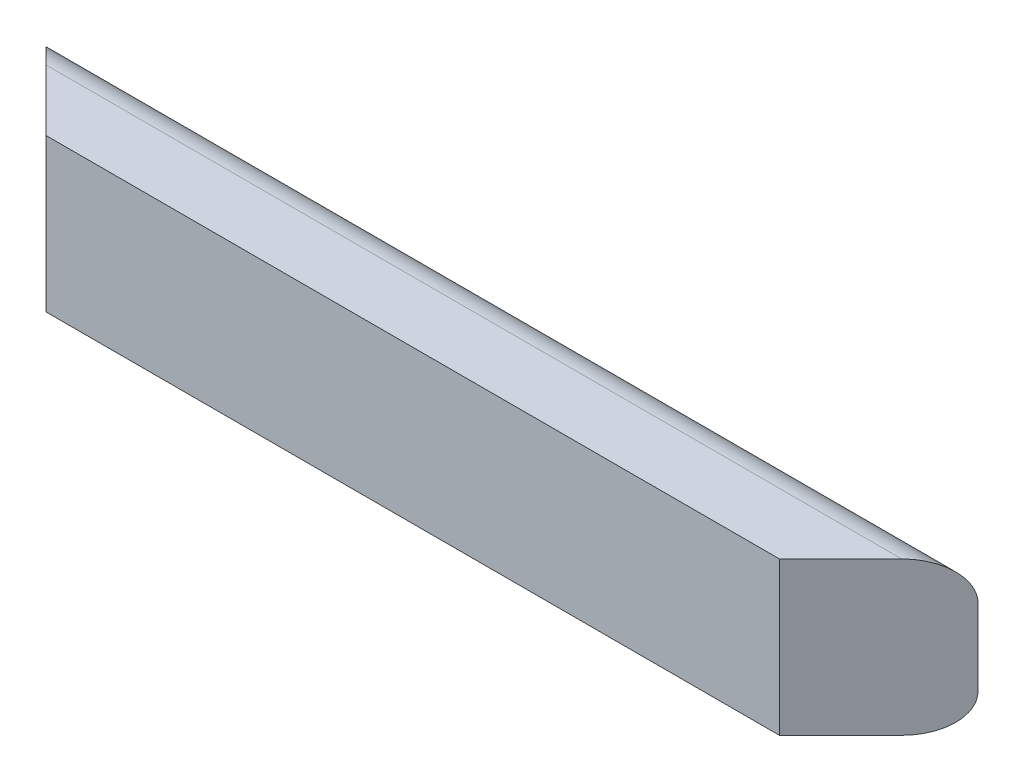
from build123d import *

# Parameters (mm, degrees)
BOSS_EXTRUDE1_DEPTH = 774.7
SKETCH2_W           = 344.402501539
SKETCH2_H           = 780.457540957
CUT_EXTRUDE1_DEPTH  = 59.371664787


with BuildPart() as part:
    # Sketch1 → Boss-Extrude1 (new body)
    with BuildSketch(Plane(origin=(0, 0, 0), x_dir=(0, 0, -1), z_dir=(1, 0, 0))):
        with BuildLine():
            Line((0, 0), (31.75, 0))
            ThreePointArc((31.75, 0), (54.200640303, 9.299359697), (63.5, 31.75))
            Line((63.5, 31.75), (63.5, 95.25))
            ThreePointArc((63.5, 95.25), (54.200640303, 117.700640303), (31.75, 127))
            Line((31.75, 127), (0, 127))
            Line((0, 127), (-19.05, 127))
            Line((-19.05, 127), (-19.05, 0))
            Line((-19.05, 0), (0, 0))
        make_face()
    extrude(amount=BOSS_EXTRUDE1_DEPTH)

    # Sketch2 → Cut-Extrude1 (cut, through all)
    with BuildSketch(Plane(origin=(355.6, 0, 355.6), x_dir=(0, 1, 0), z_dir=(0.707106781, 0, 0.707106781))):
        with Locations((32.995160032, -592.696903991)):
            Rectangle(SKETCH2_W, SKETCH2_H)
    cut_extrude1 = extrude(amount=CUT_EXTRUDE1_DEPTH, mode=Mode.SUBTRACT)

    # Mirror1: Cut-Extrude1 across plane
    add(cut_extrude1.mirror(Plane(origin=(387.35, 0, 0), x_dir=(0, 0, 1), z_dir=(1, 0, 0))), mode=Mode.SUBTRACT)


solid = part.part
